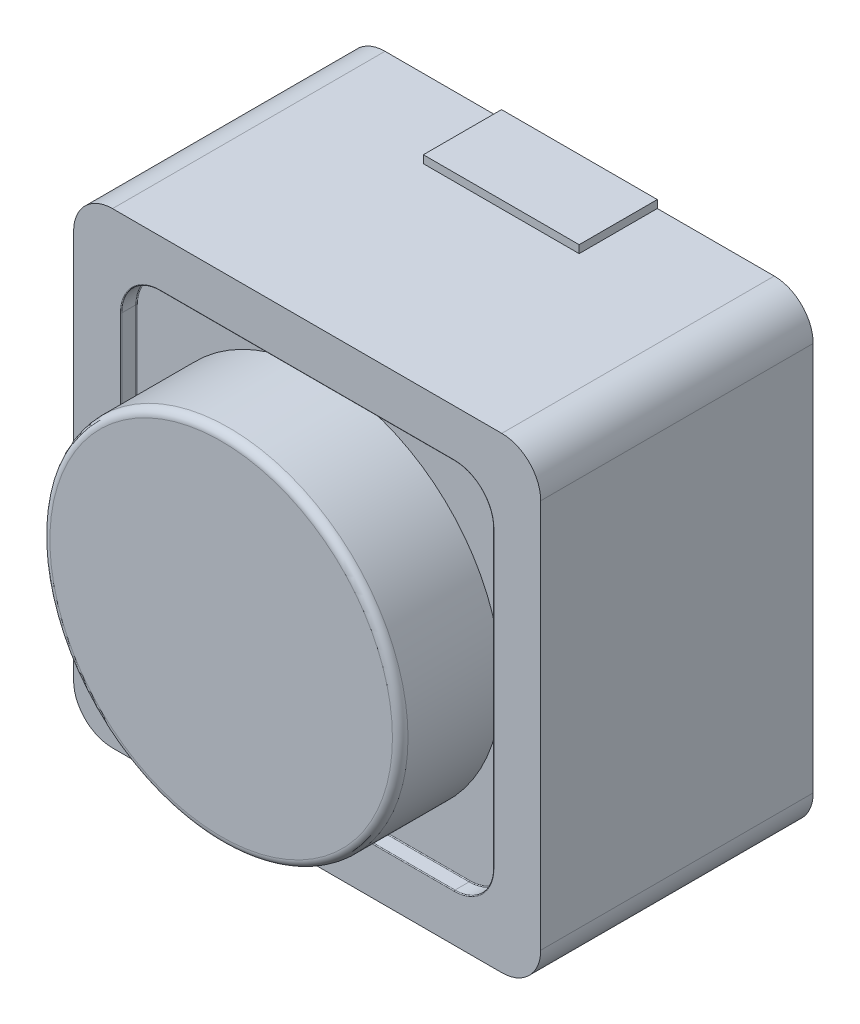
from build123d import *

# Parameters (mm, degrees)
BOSS_EXTRU_1_DEPTH      = 3.5
ENL_V_MAT_EXTRU_1_DEPTH = 0.2
ESQUISSE3_R             = 2.3
BOSS_EXTRU_2_DEPTH      = 1.3
CONG_1_R                = 0.1
CONG_2_R                = 0.01
ESQUISSE4_W             = 1.998545811
ESQUISSE4_H             = 1.004796591
BOSS_EXTRU_3_DEPTH      = 0.1
ESQUISSE5_W             = 2.001116517
ESQUISSE5_H             = 1.004085413
BOSS_EXTRU_4_DEPTH      = 0.1


with BuildPart() as part:
    # Esquisse1 → Boss.-Extru.1 (new body)
    with BuildSketch(Plane.XY):
        with BuildLine():
            Line((0.5, 0), (5.5, 0))
            ThreePointArc((5.5, 0), (5.853553391, 0.146446609), (6, 0.5))
            Line((6, 0.5), (6, 5.5))
            ThreePointArc((6, 5.5), (5.853553391, 5.853553391), (5.5, 6))
            Line((5.5, 6), (0.5, 6))
            ThreePointArc((0.5, 6), (0.146446609, 5.853553391), (0, 5.5))
            Line((0, 5.5), (0, 0.5))
            ThreePointArc((0, 0.5), (0.146446609, 0.146446609), (0.5, 0))
        make_face()
    extrude(amount=BOSS_EXTRU_1_DEPTH)

    # Esquisse2 → Enlèv. mat.-Extru.1 (cut)
    with BuildSketch(Plane.XY.offset(3.5)):
        with BuildLine():
            Line((1.11, 0.61), (4.89, 0.61))
            ThreePointArc((4.89, 0.61), (5.243553391, 0.756446609), (5.39, 1.11))
            Line((5.39, 1.11), (5.39, 4.89))
            ThreePointArc((5.39, 4.89), (5.243553391, 5.243553391), (4.89, 5.39))
            Line((4.89, 5.39), (1.11, 5.39))
            ThreePointArc((1.11, 5.39), (0.756446609, 5.243553391), (0.61, 4.89))
            Line((0.61, 4.89), (0.61, 1.11))
            ThreePointArc((0.61, 1.11), (0.756446609, 0.756446609), (1.11, 0.61))
        make_face()
    extrude(amount=-ENL_V_MAT_EXTRU_1_DEPTH, mode=Mode.SUBTRACT)

    # Esquisse3 → Boss.-Extru.2 (add)
    with BuildSketch(Plane.XY.offset(3.3)):
        with Locations((2.9955811, 3.011293081)):
            Circle(ESQUISSE3_R)
    extrude(amount=BOSS_EXTRU_2_DEPTH)

    # Congé1
    cong_1_edges = [part.edges().sort_by_distance(p)[0] for p in [
        (0.6955811, 3.011293081, 4.6),
    ]]
    fillet(cong_1_edges, radius=CONG_1_R)

    # Congé2
    cong_2_edges = [part.edges().sort_by_distance(p)[0] for p in [
        (5.243553391, 0.756446609, 3.3),
        (3, 0.61, 3.3),
        (0.756446609, 0.756446609, 3.3),
        (0.61, 3, 3.3),
        (0.756446609, 5.243553391, 3.3),
        (3, 5.39, 3.3),
        (5.243553391, 5.243553391, 3.3),
        (5.39, 3, 3.3),
        (5.243553391, 0.756446609, 3.5),
        (5.39, 3, 3.5),
        (5.243553391, 5.243553391, 3.5),
        (3, 5.39, 3.5),
        (0.756446609, 5.243553391, 3.5),
        (0.61, 3, 3.5),
        (0.756446609, 0.756446609, 3.5),
        (3, 0.61, 3.5),
    ]]
    fillet(cong_2_edges, radius=CONG_2_R)

    # Esquisse4 → Boss.-Extru.3 (add)
    with BuildSketch(Plane.XZ):
        with Locations((2.998734602, 0.502398296)):
            Rectangle(ESQUISSE4_W, ESQUISSE4_H)
    extrude(amount=BOSS_EXTRU_3_DEPTH)

    # Esquisse5 → Boss.-Extru.4 (add)
    with BuildSketch(Plane(origin=(0, 6, 0), x_dir=(1, 0, 0), z_dir=(0, 1, 0))):
        with Locations((2.997449249, -0.502042707)):
            Rectangle(ESQUISSE5_W, ESQUISSE5_H)
    extrude(amount=BOSS_EXTRU_4_DEPTH)


solid = part.part
